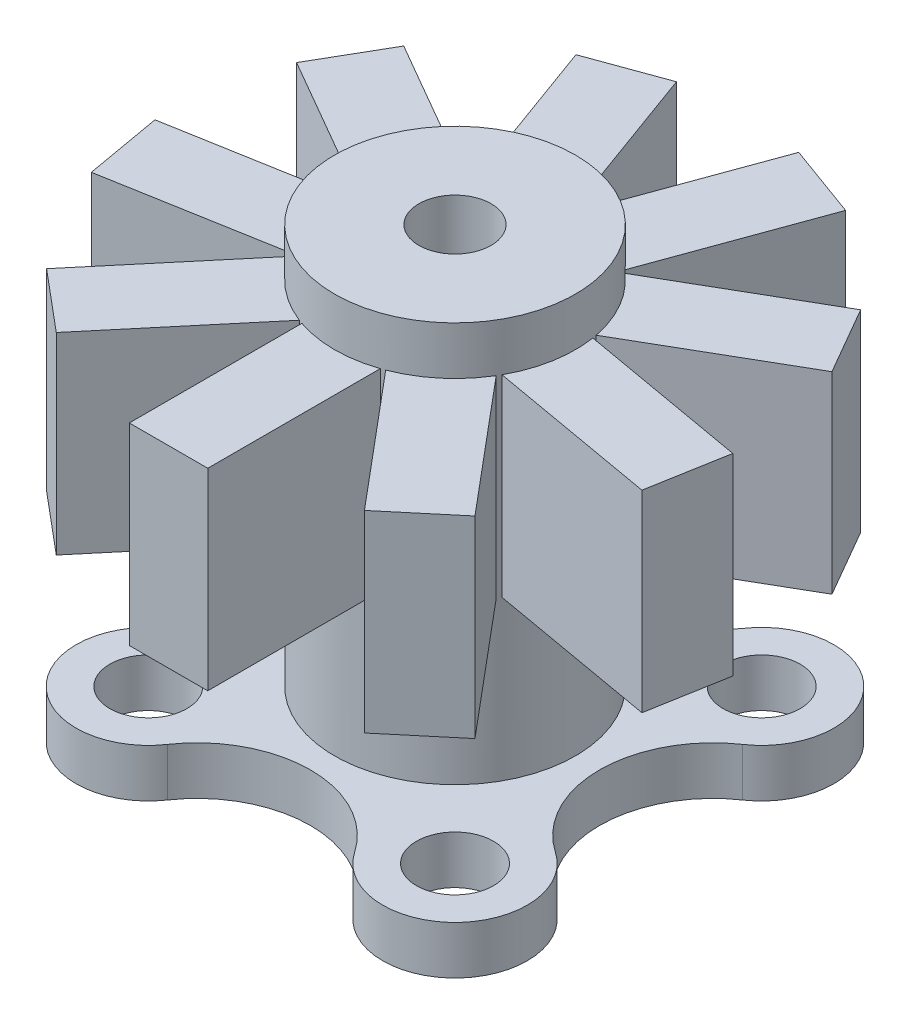
from build123d import *

# Parameters (mm, degrees)
SKETCH1_R                 = 2.5
BOSS_EXTRUDE1_DEPTH       = 9.3
BOSS_EXTRUDE2_START       = -1
SKETCH3_W                 = 1.627840772
SKETCH3_H                 = 5.944538132
BOSS_EXTRUDE2_DEPTH       = 4
CIRPATTERN1_COUNT         = 9
BOSS_EXTRUDE3_DEPTH       = 1
M2X0_4_TAPPED_HOLE1_D     = 1.6
M2X0_4_TAPPED_HOLE1_DEPTH = 1
SKETCH7_R                 = 0.75
CUT_EXTRUDE1_DEPTH        = 10.3


with BuildPart() as part:
    # Sketch1 → Boss-Extrude1 (new body)
    with BuildSketch(Plane(origin=(0, 0, 0), x_dir=(1, 0, 0), z_dir=(0, 1, 0))):
        Circle(SKETCH1_R)
    extrude(amount=BOSS_EXTRUDE1_DEPTH)

    # Sketch3 → Boss-Extrude2 (add)
    with BuildSketch(Plane(origin=(0, 9.3, 0), x_dir=(1, 0, 0), z_dir=(0, 1, 0)).offset(BOSS_EXTRUDE2_START)):
        with Locations((0, -2.972269066)):
            Rectangle(SKETCH3_W, SKETCH3_H)
    boss_extrude2 = extrude(amount=-BOSS_EXTRUDE2_DEPTH)

    # CirPattern1: Boss-Extrude2 ×9 about axis
    cirpattern1_axis = Axis((0, 0, 0), (0, 1, 0))
    for i in range(1, CIRPATTERN1_COUNT):
        add(boss_extrude2.rotate(cirpattern1_axis, i * 360 / CIRPATTERN1_COUNT))

    # Sketch4 → Boss-Extrude3 (add)
    with BuildSketch(Plane.XZ):
        with BuildLine():
            ThreePointArc((-1.942516625, 4.026805507), (-4.242640687, 4.242640687), (-4.026805507, 1.942516625))
            ThreePointArc((-4.026805507, 1.942516625), (-3, 0), (-4.026805507, -1.942516625))
            ThreePointArc((-4.026805507, -1.942516625), (-4.242640687, -4.242640687), (-1.942516625, -4.026805507))
            ThreePointArc((-1.942516625, -4.026805507), (0, -3), (1.942516625, -4.026805507))
            ThreePointArc((1.942516625, -4.026805507), (4.242640687, -4.242640687), (4.026805507, -1.942516625))
            ThreePointArc((4.026805507, -1.942516625), (3, 0), (4.026805507, 1.942516625))
            ThreePointArc((4.026805507, 1.942516625), (4.242640687, 4.242640687), (1.942516625, 4.026805507))
            ThreePointArc((1.942516625, 4.026805507), (0, 3), (-1.942516625, 4.026805507))
        make_face()
    extrude(amount=-BOSS_EXTRUDE3_DEPTH)

    # M2x0.4 Tapped Hole1
    with Locations(Plane(origin=(0, 0, 0), x_dir=(-1, 0, 0), z_dir=(0, -1, 0))):
        with Locations((3.181980515, 3.181980515), (-3.181980515, 3.181980515), (-3.181980515, -3.181980515), (3.181980515, -3.181980515)):
            Hole(M2X0_4_TAPPED_HOLE1_D / 2, depth=M2X0_4_TAPPED_HOLE1_DEPTH)

    # Sketch7 → Cut-Extrude1 (cut, through all)
    with BuildSketch(Plane.XZ):
        Circle(SKETCH7_R)
    extrude(amount=-CUT_EXTRUDE1_DEPTH, mode=Mode.SUBTRACT)


solid = part.part
